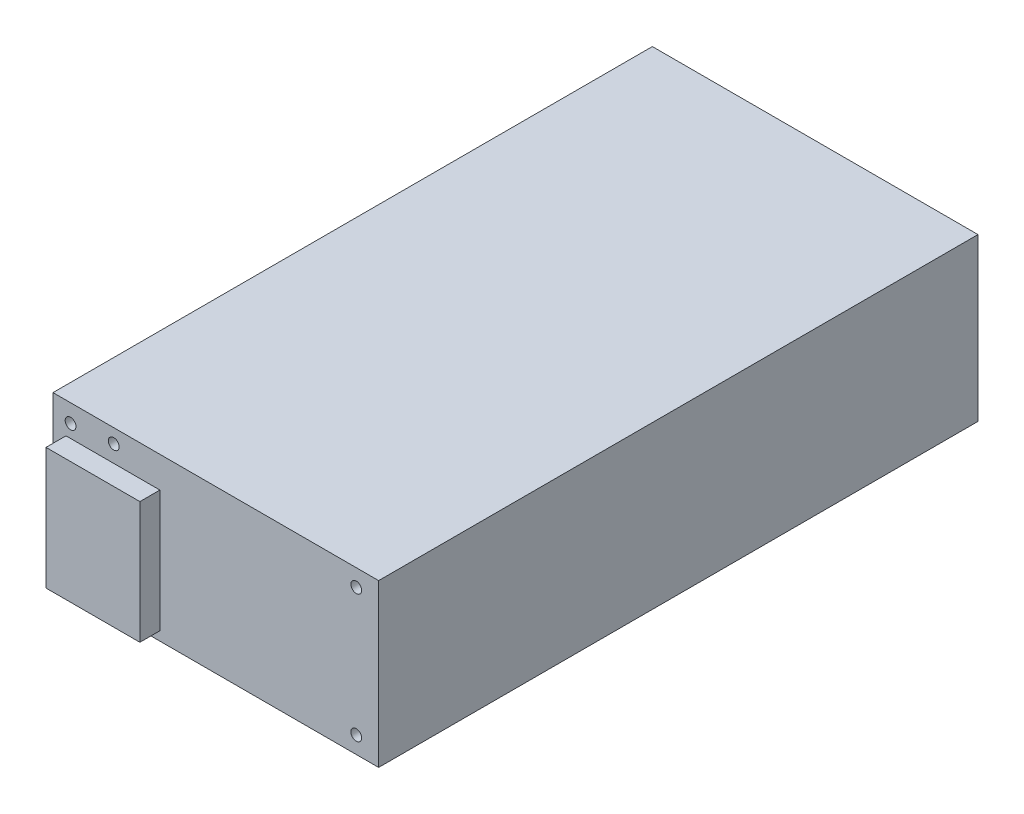
from build123d import *

# Parameters (mm, degrees)
SKETCH1_W                 = 150
SKETCH1_H                 = 40.5
MAIN_BODY_DEPTH           = 81.5
F_6_32_TAPPED_HOLE2_D     = 2.7051
F_6_32_TAPPED_HOLE2_DEPTH = 5
F_6_32_TAPPED_HOLE2_TIP   = 0.81269403
SKETCH7_W                 = 23.5
SKETCH7_H                 = 30.5
BOSS_EXTRUDE1_DEPTH       = 5


with BuildPart() as part:
    # Sketch1 → main-body (new body)
    with BuildSketch(Plane(origin=(0, 0, 0), x_dir=(0, 0, -1), z_dir=(1, 0, 0))):
        with Locations((75, 20.25)):
            Rectangle(SKETCH1_W, SKETCH1_H)
    extrude(amount=MAIN_BODY_DEPTH)

    # #6-32 Tapped Hole2
    with Locations(Plane.XY):
        with Locations((4.4, 36), (15.2, 37), (75.9, 36.25), (75.9, 4.25)):
            Hole(F_6_32_TAPPED_HOLE2_D / 2, depth=F_6_32_TAPPED_HOLE2_DEPTH)
            with Locations((0, 0, -(F_6_32_TAPPED_HOLE2_DEPTH + F_6_32_TAPPED_HOLE2_TIP / 2))):  # 118° drill point
                Cone(0, F_6_32_TAPPED_HOLE2_D / 2, F_6_32_TAPPED_HOLE2_TIP, mode=Mode.SUBTRACT)

    # Sketch7 → Boss-Extrude1 (add)
    with BuildSketch(Plane.XY):
        with Locations((15, 17.5)):
            Rectangle(SKETCH7_W, SKETCH7_H)
    extrude(amount=BOSS_EXTRUDE1_DEPTH)


solid = part.part
